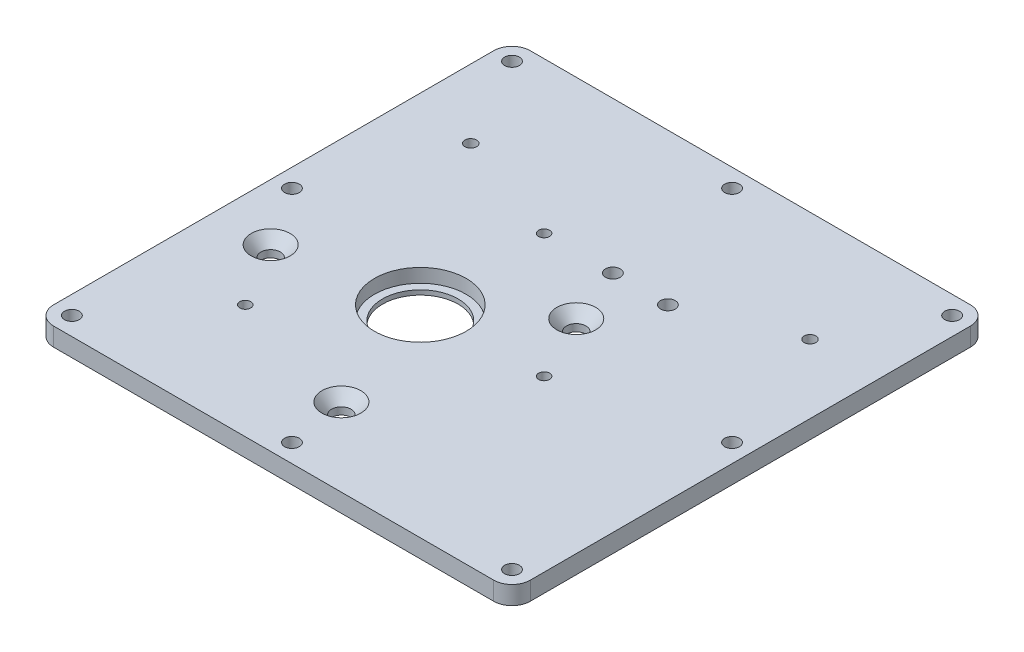
from build123d import *

# Parameters (mm, degrees)
SKETCH1_W                                    = 165.1
SKETCH1_H                                    = 165.1
SKETCH1_R                                    = 13.096875
SKETCH1_R_2                                  = 1.5875
BOSS_EXTRUDE1_DEPTH                          = 6.35
SKETCH3_R                                    = 15.875
CUT_EXTRUDE1_DEPTH                           = 4.7625
CSK_FOR_1_4_FLAT_HEAD_SOCKET_CAP_SCR_2_COUNT = 2
CSK_FOR_1_4_FLAT_HEAD_SOCKET_CAP_SCR_2_PITCH = 81.129190467
CSK_FOR_1_4_FLAT_HEAD_SOCKET_CAP_SCR_3_COUNT = 2
CSK_FOR_1_4_FLAT_HEAD_SOCKET_CAP_SCR_3_PITCH = 68.88094119
FILLET1_R                                    = 6.35
F_10_CLEARANCE_HOLE1_D                       = 5.1054
F_10_24_TAPPED_HOLE1_D                       = 3.7973
F_10_24_TAPPED_HOLE1_DEPTH                   = 16.002
F_10_24_TAPPED_HOLE1_TIP                     = 1.140824014
F_10_CLEARANCE_HOLE2_D                       = 5.1054
SKETCH16_R                                   = 19.446875
SKETCH16_R_2                                 = 9.7282
SKETCH16_R_3                                 = 8.24865
CUT_EXTRUDE2_DEPTH                           = 3.175
FILLET2_R                                    = 3.175
F_10_32_TAPPED_HOLE1_D                       = 4.0386


with BuildPart() as part:
    # Sketch1 → Boss-Extrude1 (new body)
    with BuildSketch(Plane(origin=(0, 0, 0), x_dir=(1, 0, 0), z_dir=(0, 1, 0))):
        Rectangle(SKETCH1_W, SKETCH1_H)
        with Locations((-19.05, -12.7)):
            Circle(SKETCH1_R, mode=Mode.SUBTRACT)
        with Locations((23.8125, -12.7)):
            Circle(SKETCH1_R_2, mode=Mode.SUBTRACT)
    extrude(amount=BOSS_EXTRUDE1_DEPTH)

    # Sketch3 → Cut-Extrude1 (cut)
    with BuildSketch(Plane.XZ.offset(-6.35)):
        with Locations((-19.05, 12.7)):
            Circle(SKETCH3_R)
    extrude(amount=CUT_EXTRUDE1_DEPTH, mode=Mode.SUBTRACT)

    # Sketch8 → CSK for 1/4 Flat Head Socket Cap Screw1 (revolve, cut)
    with BuildSketch(Plane(origin=(-62.992, 6.35, 20.574), x_dir=(0, 0, 1), z_dir=(1, 0, 0))):
        Polygon((0, 0), (0, 6.35), (3.3782, 6.35), (3.3782, 3.871564875), (6.7437, 0), align=None)
    csk_for_1_4_flat_head_socket_cap_screw1 = revolve(axis=Axis((-62.992, 12.7, 20.574), (0, -1, 0)), mode=Mode.SUBTRACT)

    # CSK for 1_4 Flat Head Socket Cap Scr 2: CSK for 1/4 Flat Head Socket Cap Screw1 ×2
    with Locations(*[Vector(0.925467142, 0, -0.378827889) * (i * CSK_FOR_1_4_FLAT_HEAD_SOCKET_CAP_SCR_2_PITCH) for i in range(1, CSK_FOR_1_4_FLAT_HEAD_SOCKET_CAP_SCR_2_COUNT)]):
        add(csk_for_1_4_flat_head_socket_cap_screw1, mode=Mode.SUBTRACT)

    # CSK for 1_4 Flat Head Socket Cap Scr 3: CSK for 1/4 Flat Head Socket Cap Screw1 ×2
    with Locations(*[Vector(0.862142691, 0, 0.506665551) * (i * CSK_FOR_1_4_FLAT_HEAD_SOCKET_CAP_SCR_3_PITCH) for i in range(1, CSK_FOR_1_4_FLAT_HEAD_SOCKET_CAP_SCR_3_COUNT)]):
        add(csk_for_1_4_flat_head_socket_cap_screw1, mode=Mode.SUBTRACT)

    # Fillet1
    fillet1_edges = [part.edges().sort_by_distance(p)[0] for p in [
        (-82.55, 3.175, -82.55),
        (82.55, 3.175, -82.55),
        (82.55, 3.175, 82.55),
        (-82.55, 3.175, 82.55),
    ]]
    fillet(fillet1_edges, radius=FILLET1_R)

    # #10 Clearance Hole1 (through all)
    with Locations(Plane(origin=(0, 6.35, 0), x_dir=(1, 0, 0), z_dir=(0, 1, 0))):
        with Locations((-76.2, -76.2), (-76.2, 76.2), (76.2, 76.2), (76.2, -76.2), (0, 76.2), (0, -76.2), (-76.2, 0), (76.2, 0)):
            Hole(F_10_CLEARANCE_HOLE1_D / 2)

    # #10-24 Tapped Hole1
    with Locations(Plane(origin=(0, 6.35, 0), x_dir=(1, 0, 0), z_dir=(0, 1, 0))):
        with Locations((23.8125, -12.7), (-49.358364409, -43.008364409), (-19.05, 30.1625), (-19.05, -12.7)):
            Hole(F_10_24_TAPPED_HOLE1_D / 2, depth=F_10_24_TAPPED_HOLE1_DEPTH)
            with Locations((0, 0, -(F_10_24_TAPPED_HOLE1_DEPTH + F_10_24_TAPPED_HOLE1_TIP / 2))):  # 118° drill point
                Cone(0, F_10_24_TAPPED_HOLE1_D / 2, F_10_24_TAPPED_HOLE1_TIP, mode=Mode.SUBTRACT)

    # #10 Clearance Hole2 (through all)
    with Locations(Plane(origin=(0, 6.35, 0), x_dir=(1, 0, 0), z_dir=(0, 1, 0))):
        with Locations((23.8125, 30.1625), (4.7625, 30.1625)):
            Hole(F_10_CLEARANCE_HOLE2_D / 2)

    # Sketch16 → Cut-Extrude2 (cut)
    with BuildSketch(Plane.XZ):
        with BuildLine():
            Line((69.85, -69.85), (-69.85, -69.85))
            Line((-69.85, -69.85), (-69.85, 13.674310787))
            ThreePointArc((-69.85, 13.674310787), (-53.2638, 20.574), (-69.85, 27.473689213))
            Line((-69.85, 27.473689213), (-69.85, 69.85))
            Line((-69.85, 69.85), (69.85, 69.85))
            Line((69.85, 69.85), (69.85, -69.85))
        make_face()
        with Locations((-19.05, 12.7)):
            Circle(SKETCH16_R, mode=Mode.SUBTRACT)
        with Locations((-3.6068, 55.4736)):
            Circle(SKETCH16_R_2, mode=Mode.SUBTRACT)
        with Locations((23.8125, 12.7)):
            Circle(SKETCH16_R_3, mode=Mode.SUBTRACT)
        with Locations((-19.05, -30.1625)):
            Circle(SKETCH16_R_3, mode=Mode.SUBTRACT)
        with Locations((-49.358364409, 43.008364409)):
            Circle(SKETCH16_R_3, mode=Mode.SUBTRACT)
        with BuildLine():
            ThreePointArc((20.819224907, -14.454821414), (11.727367105, -0.438576115), (3.70620807, -15.093882946))
            ThreePointArc((3.70620807, -15.093882946), (4.113625171, -19.033669627), (1.400289966, -21.919101976))
            ThreePointArc((1.400289966, -21.919101976), (-2.687905399, -35.035848611), (10.967913569, -36.546143923))
            ThreePointArc((10.967913569, -36.546143923), (14.2875, -35.198574694), (17.607086431, -36.546143923))
            ThreePointArc((17.607086431, -36.546143923), (31.895360473, -33.894179765), (24.646386862, -21.298939768))
            ThreePointArc((24.646386862, -21.298939768), (20.935730068, -18.881787262), (20.819224907, -14.454821414))
        make_face(mode=Mode.SUBTRACT)
    extrude(amount=-CUT_EXTRUDE2_DEPTH, mode=Mode.SUBTRACT)

    # Fillet2
    fillet2_edges = [part.edges().sort_by_distance(p)[0] for p in [
        (-69.85, 1.5875, 13.674310787),
        (-69.85, 1.5875, 27.473689213),
        (-69.85, 1.5875, 69.85),
        (69.85, 1.5875, 69.85),
        (69.85, 1.5875, -69.85),
        (-69.85, 1.5875, -69.85),
    ]]
    fillet(fillet2_edges, radius=FILLET2_R)

    # #10-32 Tapped Hole1 (through all)
    with Locations(Plane(origin=(0, 6.35, 0), x_dir=(1, 0, 0), z_dir=(0, 1, 0))):
        with Locations((58.7375, 44.45), (-58.7375, 44.45)):
            Hole(F_10_32_TAPPED_HOLE1_D / 2)


solid = part.part
